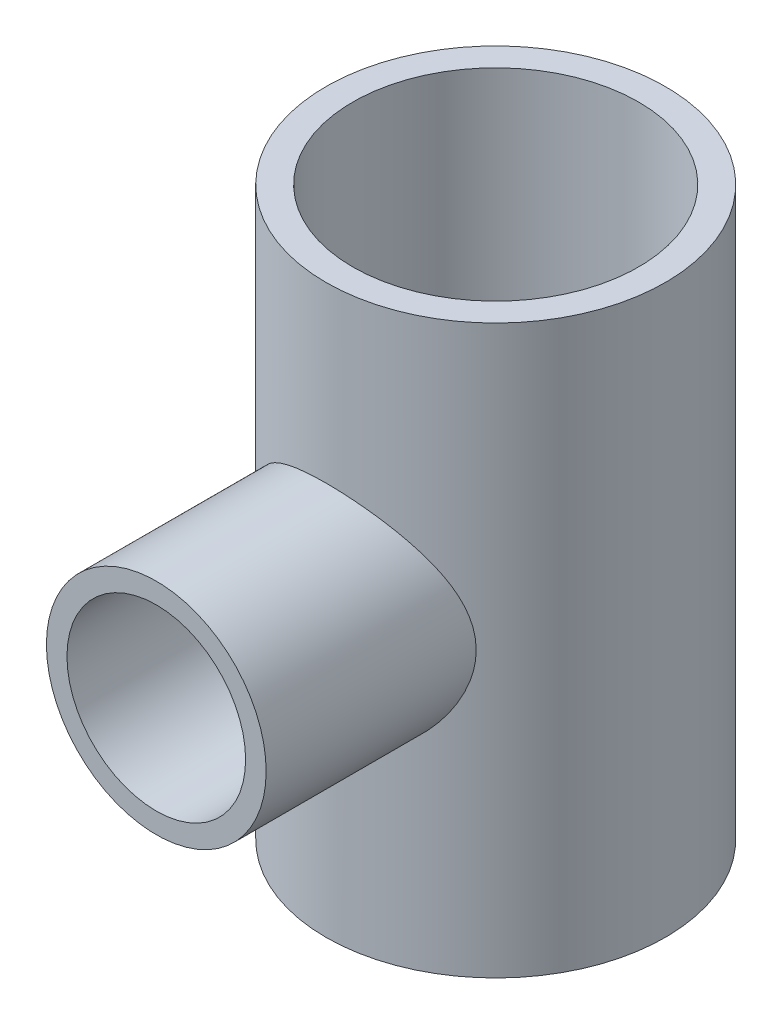
from build123d import *

# Parameters (mm, degrees)
SKETCH_1_R          = 19
SKETCH_1_R_2        = 16
EXTRUDE_1_DEPTH     = 63.5
SKETCH_2_R          = 12.3
SKETCH_2_R_2        = 10
EXTRUDE_2_DEPTH     = 38
SKETCH_3_R          = 16
CUT_EXTRUDE_1_DEPTH = 64.5000001
CUT_EXTRUDE_2_REACH = 59
SKETCH_7_R          = 10


with BuildPart() as part:
    # 草图1 → 凸台-拉伸1 (new body)
    with BuildSketch(Plane(origin=(0, 0, 0), x_dir=(1, 0, 0), z_dir=(0, 1, 0))):
        Circle(SKETCH_1_R)
        Circle(SKETCH_1_R_2, mode=Mode.SUBTRACT)
    extrude(amount=EXTRUDE_1_DEPTH)

    # 草图2 → 凸台-拉伸2 (add)
    with BuildSketch(Plane.XY):
        with Locations((0, 31.75)):
            Circle(SKETCH_2_R)
        with Locations((0, 31.75)):
            Circle(SKETCH_2_R_2, mode=Mode.SUBTRACT)
    extrude(amount=EXTRUDE_2_DEPTH)

    # 草图3 → 切除-拉伸1 (cut, through all)
    with BuildSketch(Plane.XZ):
        Circle(SKETCH_3_R)
    extrude(amount=-CUT_EXTRUDE_1_DEPTH, mode=Mode.SUBTRACT)

    # 草图7 → 切除-拉伸2 (cut, up to next)
    with BuildSketch(Plane.XY.offset(38), mode=Mode.PRIVATE) as cut_extrude_2_sk1:
        with Locations((0, 31.75)):
            Circle(SKETCH_7_R)
    cut_extrude_2_tool1 = extrude(cut_extrude_2_sk1.sketch, amount=-CUT_EXTRUDE_2_REACH, mode=Mode.PRIVATE) & part.part
    add(cut_extrude_2_tool1.solids().sort_by_distance((0, 31.75, 38))[0], mode=Mode.SUBTRACT)


solid = part.part
